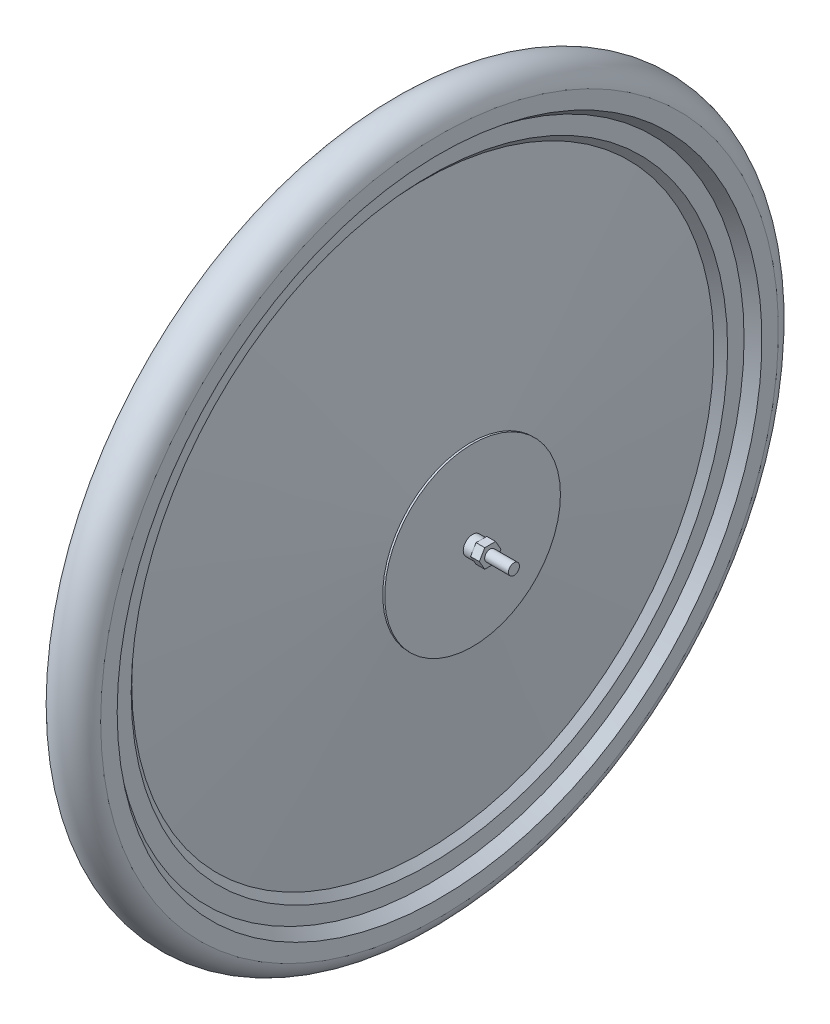
from build123d import *
from build123d.topology import SkipClean

# Parameters (mm, degrees)
SKETCH1_R           = 17.5
BOSS_EXTRUDE1_DEPTH = 39
FILLET1_R           = 4.5
SKETCH2_R           = 5
BOSS_EXTRUDE2_DEPTH = 90
SKETCH6_W           = 6
SKETCH6_H           = 26
SKETCH6_W_2         = 14
SKETCH6_W_3         = 18.119457468
SKETCH6_H_2         = 239
SKETCH6_W_4         = 26
SKETCH6_H_3         = 15
SKETCH7_W           = 44.5
SKETCH7_H           = 15
SKETCH8_R           = 28.3
BOSS_EXTRUDE5_DEPTH = 6.5
SKETCH9_R           = 80
BOSS_EXTRUDE6_DEPTH = 1.8
BOSS_EXTRUDE7_START = 13.3
SKETCH10_R          = 8.5
SKETCH10_R_2        = 7.120417841
SKETCH10_R_3        = 5
BOSS_EXTRUDE7_DEPTH = 8
BOSS_EXTRUDE8_START = 21.3
SKETCH10_3_R        = 8.5
SKETCH10_3_R_2      = 7.120417841
SKETCH10_3_R_3      = 5
BOSS_EXTRUDE8_DEPTH = 8
SKETCH14_R          = 28.5
SKETCH14_R_2        = 19.5
BOSS_EXTRUDE9_DEPTH = 26.880542532


with BuildPart() as part:
    # Sketch1 → Boss-Extrude1 (new, symmetric)
    with BuildSketch(Plane(origin=(0, 0, 0), x_dir=(0, 0, -1), z_dir=(1, 0, 0))):
        Circle(SKETCH1_R)
    extrude(amount=BOSS_EXTRUDE1_DEPTH, both=True)

    # Fillet1
    fillet1_edges = [part.edges().sort_by_distance(p)[0] for p in [
        (-39, 0, 17.5),
        (39, 0, 17.5),
    ]]
    fillet(fillet1_edges, radius=FILLET1_R)

    # Sketch2 → Boss-Extrude2 (add, symmetric)
    with BuildSketch(Plane(origin=(0, 0, 0), x_dir=(0, 0, -1), z_dir=(1, 0, 0))):
        with Locations(Location((0, 0, 0), (0, 0, 180))):
            Circle(SKETCH2_R)
    extrude(amount=BOSS_EXTRUDE2_DEPTH, both=True)

    # Sketch6 → Revolve1 (revolve)
    with SkipClean():  # the faces are left unmerged after this step: merging them gives an invalid solid
        with BuildSketch(Plane.XY, mode=Mode.PRIVATE) as revolve1_sk:
            with Locations((-10, 13)):
                Rectangle(SKETCH6_W, SKETCH6_H)
            with Locations((0, 13)):
                Rectangle(SKETCH6_W_2, SKETCH6_H)
            with Locations((10, 13)):
                Rectangle(SKETCH6_W, SKETCH6_H)
            with Locations((-22.059728734, 13)):
                Rectangle(SKETCH6_W_3, SKETCH6_H)
            with Locations((22.059728734, 13)):
                Rectangle(SKETCH6_W_3, SKETCH6_H)
            Polygon((13, 205.545926379), (13, 26), (31.119457468, 26), align=None)
            Polygon((7, 265), (7, 26), (13, 26), (13, 205.545926379), align=None)
            with Locations((0, 145.5)):
                Rectangle(SKETCH6_W_2, SKETCH6_H_2)
            Polygon((-13, 205.545926379), (-13, 26), (-7, 26), (-7, 265), align=None)
            Polygon((-13, 205.545926379), (-31.119457468, 26), (-13, 26), align=None)
            Polygon((-7, 265), (7, 265), (13, 271.5), (-13, 271.5), align=None)
            with Locations((0, 279)):
                Rectangle(SKETCH6_W_4, SKETCH6_H_3)
        revolve(revolve1_sk.sketch.rotate(Axis((-31.119457468, 0, 0), (1, 0, 0)), 90), axis=Axis((-31.119457468, 0, 0), (1, 0, 0)))

    # Sketch7 → Revolve2 (revolve)
    with SkipClean():  # the faces are left unmerged after this step: merging them gives an invalid solid
        with BuildSketch(Plane.XY, mode=Mode.PRIVATE) as revolve2_sk:
            Polygon((22.25, 293.5), (13, 286.5), (-13, 286.5), (-22.25, 293.5), align=None)
            with Locations((0, 301)):
                Rectangle(SKETCH7_W, SKETCH7_H)
            with BuildLine():
                ThreePointArc((-22.25, 308.5), (0, 326.5), (22.25, 308.5))
                Line((22.25, 308.5), (-22.25, 308.5))
            make_face()
        revolve(revolve2_sk.sketch.rotate(Axis((-31.119457468, 0, 0), (1, 0, 0)), 90), axis=Axis((-31.119457468, 0, 0), (1, 0, 0)))

    # Sketch8 → Boss-Extrude5 (add)
    with SkipClean():  # the faces are left unmerged after this step: merging them gives an invalid solid
        with BuildSketch(Plane(origin=(50.5, 0, 0), x_dir=(0, 0, -1), z_dir=(1, 0, 0))):
            Circle(SKETCH8_R)
        extrude(amount=-BOSS_EXTRUDE5_DEPTH)

    # Sketch9 → Boss-Extrude6 (add)
    with SkipClean():  # the faces are left unmerged after this step: merging them gives an invalid solid
        with BuildSketch(Plane(origin=(50.5, 0, 0), x_dir=(0, 0, -1), z_dir=(1, 0, 0))):
            Circle(SKETCH9_R)
        extrude(amount=BOSS_EXTRUDE6_DEPTH)

    # Sketch10 → Boss-Extrude7 (add)
    with SkipClean():  # the faces are left unmerged after this step: merging them gives an invalid solid
        with BuildSketch(Plane(origin=(39, 0, 0), x_dir=(0, 0, -1), z_dir=(1, 0, 0)).offset(BOSS_EXTRUDE7_START)):
            Circle(SKETCH10_R)
            Circle(SKETCH10_R_2, mode=Mode.SUBTRACT)
            Circle(SKETCH10_R_2)
            with Locations(Location((0, 0, 0), (0, 0, 180))):
                Circle(SKETCH10_R_3, mode=Mode.SUBTRACT)
        boss_extrude7 = extrude(amount=BOSS_EXTRUDE7_DEPTH)

    # Sketch10_3 → Boss-Extrude8 (add)
    with SkipClean():  # the faces are left unmerged after this step: merging them gives an invalid solid
        with BuildSketch(Plane(origin=(39, 0, 0), x_dir=(0, 0, -1), z_dir=(1, 0, 0)).offset(BOSS_EXTRUDE8_START)):
            with BuildLine():
                ThreePointArc((-7.361215909, 4.25000004), (-4.24999998, 7.361215944), (0, 8.5))
                Line((0, 8.5), (-4.907477288, 8.5))
                Line((-4.907477288, 8.5), (-7.361215909, 4.25000004))
            make_face()
            with BuildLine():
                ThreePointArc((0, 8.5), (4.250000062, 7.361215896), (7.361216004, 4.249999875))
                Line((7.361216004, 4.249999875), (4.907477288, 8.5))
                Line((4.907477288, 8.5), (0, 8.5))
            make_face()
            with BuildLine():
                ThreePointArc((-7.361215915, -4.250000029), (-8.5, 6e-09), (-7.361215909, 4.25000004))
                Line((-7.361215909, 4.25000004), (-9.814954576, 0))
                Line((-9.814954576, 0), (-7.361215915, -4.250000029))
            make_face()
            with BuildLine():
                Line((-4.907477288, -8.5), (0, -8.5))
                ThreePointArc((0, -8.5), (-4.249999985, -7.361215941), (-7.361215915, -4.250000029))
                Line((-7.361215915, -4.250000029), (-4.907477288, -8.5))
            make_face()
            with BuildLine():
                Line((4.907477288, -8.5), (7.36121598, -4.249999918))
                ThreePointArc((7.36121598, -4.249999918), (4.250000041, -7.361215908), (0, -8.5))
                Line((0, -8.5), (4.907477288, -8.5))
            make_face()
            with BuildLine():
                Line((7.36121598, -4.249999918), (9.814954576, 0))
                Line((9.814954576, 0), (7.361216004, 4.249999875))
                ThreePointArc((7.361216004, 4.249999875), (8.210369542, 2.199961814), (8.5, 0))
                ThreePointArc((8.5, 0), (8.210369536, -2.199961837), (7.36121598, -4.249999918))
            make_face()
            with Locations(Location((0, 0, 0), (0, 0, 210))):
                Circle(SKETCH10_3_R)
            Circle(SKETCH10_3_R_2, mode=Mode.SUBTRACT)
            Circle(SKETCH10_3_R_2)
            with Locations(Location((0, 0, 0), (0, 0, 180))):
                Circle(SKETCH10_3_R_3, mode=Mode.SUBTRACT)
        boss_extrude8 = extrude(amount=BOSS_EXTRUDE8_DEPTH)

    # Mirror2: Boss-Extrude7, Boss-Extrude8 across plane
    with SkipClean():  # the faces are left unmerged after this step: merging them gives an invalid solid
        add(boss_extrude7.mirror(Plane(origin=(0, 0, 0), x_dir=(0, 0, 1), z_dir=(1, 0, 0))))
        add(boss_extrude8.mirror(Plane(origin=(0, 0, 0), x_dir=(0, 0, 1), z_dir=(1, 0, 0))))

    # Sketch14 → Boss-Extrude9 (add)
    with SkipClean():  # the faces are left unmerged after this step: merging them gives an invalid solid
        with BuildSketch(Plane.ZY.offset(58)):
            Circle(SKETCH14_R)
            Circle(SKETCH14_R_2, mode=Mode.SUBTRACT)
        extrude(amount=-BOSS_EXTRUDE9_DEPTH)


solid = part.part
